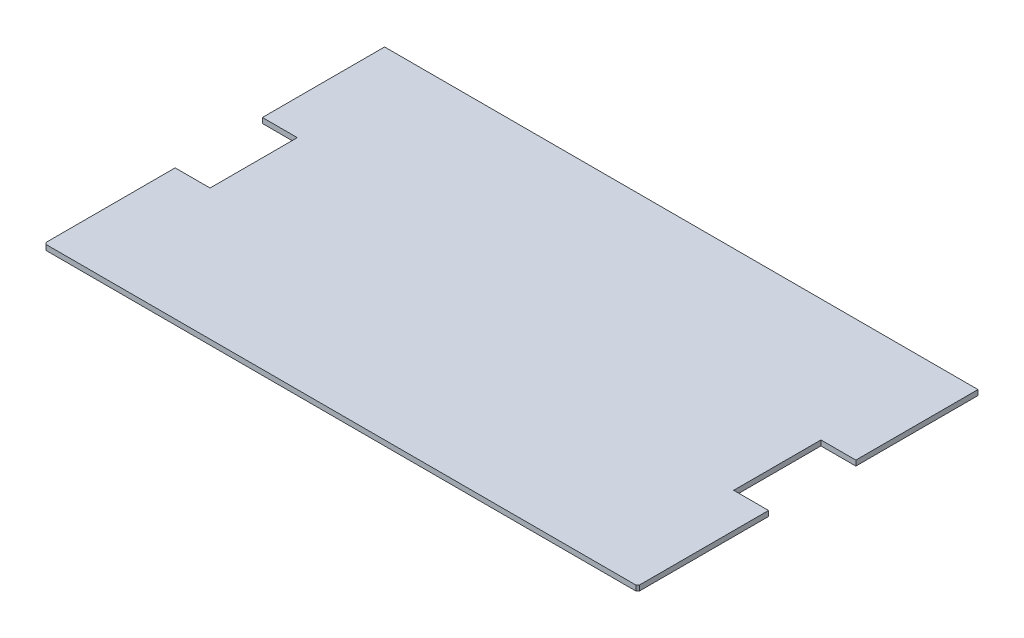
from build123d import *

# Parameters (mm, degrees)
BOSS_EXTRUDE1_DEPTH = 3
CHAMFER1_SIZE       = 1


with BuildPart() as part:
    # Sketch1 → Boss-Extrude1 (new body)
    with BuildSketch(Plane(origin=(0, 0, 0), x_dir=(1, 0, 0), z_dir=(0, 1, 0))):
        Polygon((-170, -97.5), (-170, -22.5), (-150, -22.5), (-150, 27.5), (-170, 27.5), (-170, 97.5), (170, 97.5), (170, 27.5), (150, 27.5), (150, -22.5), (170, -22.5), (170, -97.5), align=None)
    extrude(amount=BOSS_EXTRUDE1_DEPTH)

    # Chamfer1
    chamfer1_edges = [part.edges().sort_by_distance(p)[0] for p in [
        (-170, 1.5, 97.5),
        (170, 1.5, 97.5),
    ]]
    chamfer(chamfer1_edges, length=CHAMFER1_SIZE)


solid = part.part
